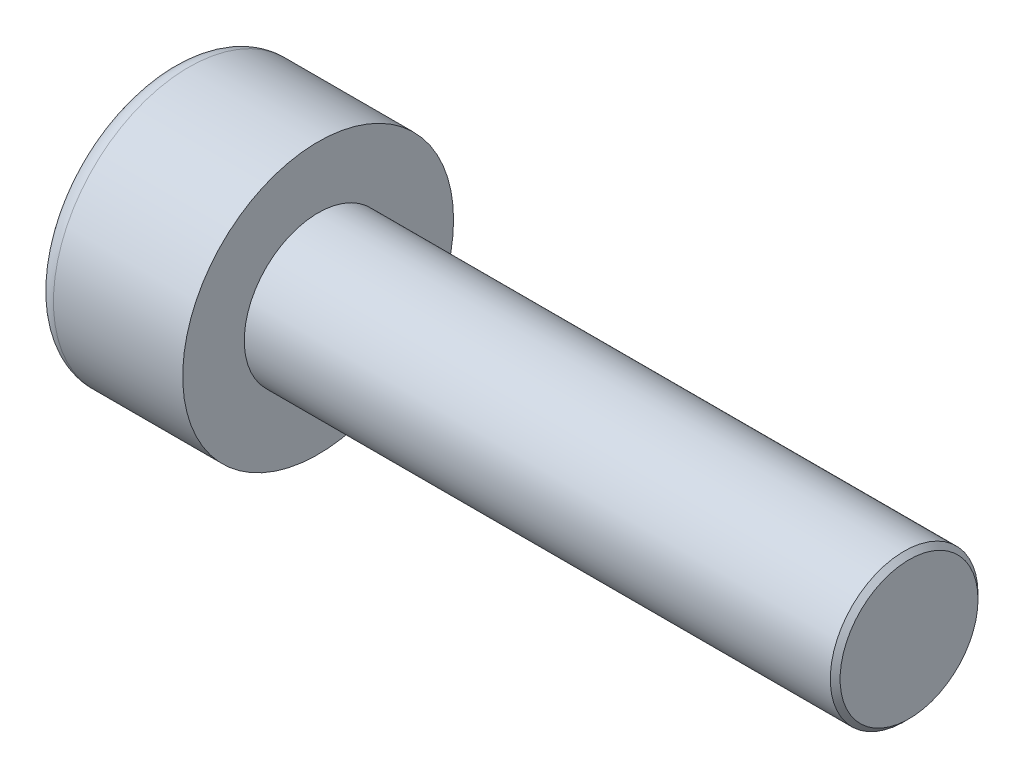
from build123d import *

# Parameters (mm, degrees)
SKETCH1_R           = 2.75
BASEHEAD_DEPTH      = 3
SKETCH2_R           = 1.5
BASEBODY_DEPTH      = 12
HEXAGONSOCKET_DEPTH = 1.3
TOPFILLET_R         = 0.375
CHAMFER1_SIZE       = 0.1


with BuildPart() as part:
    # Sketch1 → BaseHead (new body)
    with BuildSketch(Plane(origin=(0, 0, 0), x_dir=(0, 0, -1), z_dir=(1, 0, 0))):
        Circle(SKETCH1_R)
    extrude(amount=BASEHEAD_DEPTH)

    # Sketch2 → BaseBody (add)
    with BuildSketch(Plane(origin=(3, 0, 0), x_dir=(0, 0, -1), z_dir=(1, 0, 0))):
        Circle(SKETCH2_R)
    extrude(amount=BASEBODY_DEPTH)

    # Sketch3 → HexagonSocket (cut)
    with BuildSketch(Plane(origin=(0, 0, 0), x_dir=(0, 0, -1), z_dir=(1, 0, 0))):
        Polygon((1.443375673, 0), (0.721687836, 1.25), (-0.721687836, 1.25), (-1.443375673, 0), (-0.721687836, -1.25), (0.721687836, -1.25), align=None)
    extrude(amount=HEXAGONSOCKET_DEPTH, mode=Mode.SUBTRACT)

    # Sketch4 → Cut-Revolve1 (revolve, cut)
    with BuildSketch(Plane(origin=(-4.19613823, 0.75, 0), x_dir=(-1, 0, 0), z_dir=(0, 0, 1))):
        Polygon((-5.49613823, 2), (-6.217826066, 0.75), (-5.49613823, 0.75), align=None)
    revolve(axis=Axis((0.838992387, 0, 0), (-1, 0, 0)), mode=Mode.SUBTRACT)

    # TopFillet
    topfillet_edges = [part.edges().sort_by_distance(p)[0] for p in [
        (0, 0, 2.75),
    ]]
    fillet(topfillet_edges, radius=TOPFILLET_R)

    # Chamfer1
    chamfer1_edges = [part.edges().sort_by_distance(p)[0] for p in [
        (15, 0, 1.5),
    ]]
    chamfer(chamfer1_edges, length=CHAMFER1_SIZE)


solid = part.part
